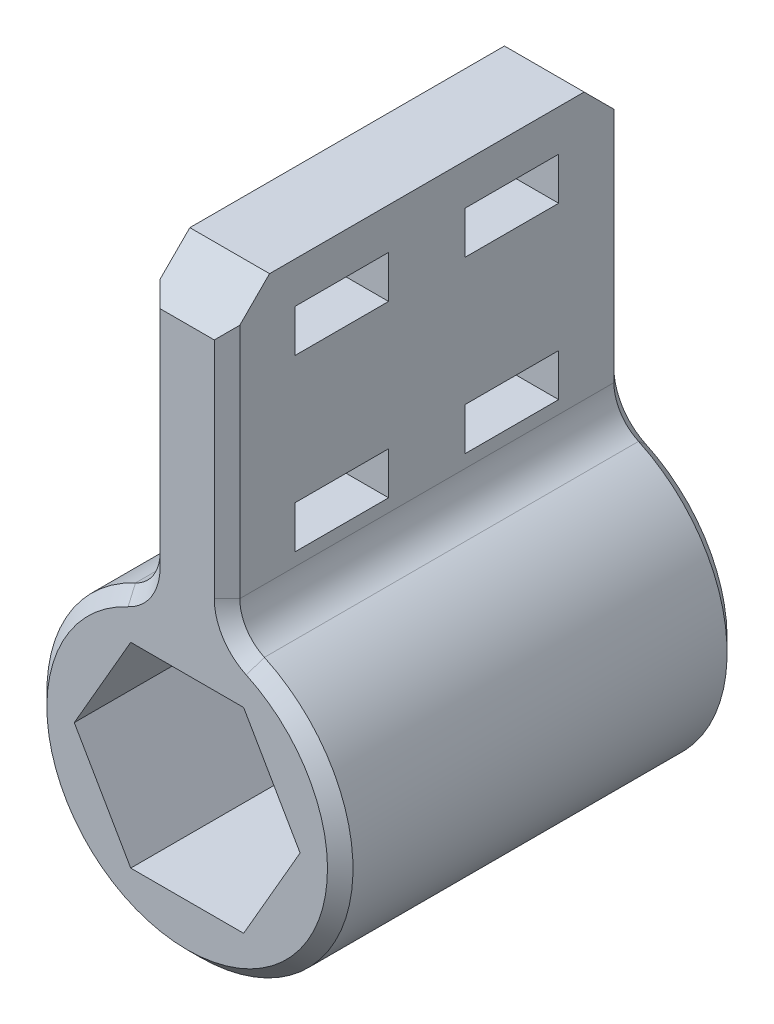
from build123d import *

# Parameters (mm, degrees)
SKETCH2_R           = 3.6
SKETCH2_R_2         = 1.625
BOSS_EXTRUDE1_DEPTH = 9.4
BOSS_EXTRUDE2_DEPTH = 9.4
SKETCH4_W           = 2.2
SKETCH4_H           = 1
CUT_EXTRUDE2_DEPTH  = 10
CHAMFER2_SIZE       = 1
FILLET1_R           = 1
CUT_EXTRUDE3_DEPTH  = 10
CHAMFER1_SIZE       = 0.3


with BuildPart() as part:
    # Sketch2 → Boss-Extrude1 (new body)
    with BuildSketch(Plane.XY):
        Circle(SKETCH2_R)
        Circle(SKETCH2_R_2, mode=Mode.SUBTRACT)
    extrude(amount=BOSS_EXTRUDE1_DEPTH)

    # Sketch3 → Boss-Extrude2 (add)
    with BuildSketch(Plane.XY.offset(9.4)):
        with BuildLine():
            Line((-0.9375, 10.44191444), (-0.9375, 3.475786781))
            ThreePointArc((-0.9375, 3.475786781), (0, 3.6), (0.9375, 3.475786781))
            Line((0.9375, 3.475786781), (0.9375, 10.44191444))
            Line((0.9375, 10.44191444), (-0.9375, 10.44191444))
        make_face()
    extrude(amount=-BOSS_EXTRUDE2_DEPTH)

    # Sketch4 → Cut-Extrude2 (cut)
    with BuildSketch(Plane.ZY.offset(0.9375)):
        with Locations((2.7, 8.975786781)):
            Rectangle(SKETCH4_W, SKETCH4_H)
        with Locations((6.7, 8.975786781)):
            Rectangle(SKETCH4_W, SKETCH4_H)
        with Locations((2.7, 4.975786781)):
            Rectangle(SKETCH4_W, SKETCH4_H)
        with Locations((6.7, 4.975786781)):
            Rectangle(SKETCH4_W, SKETCH4_H)
    extrude(amount=-CUT_EXTRUDE2_DEPTH, mode=Mode.SUBTRACT)

    # Chamfer2
    chamfer2_edges = [part.edges().sort_by_distance(p)[0] for p in [
        (0, 10.44191444, 0),
        (0, 10.44191444, 9.4),
    ]]
    chamfer(chamfer2_edges, length=CHAMFER2_SIZE)

    # Fillet1
    fillet1_edges = [part.edges().sort_by_distance(p)[0] for p in [
        (0.9375, 3.475786781, 4.7),
        (-0.9375, 3.475786781, 4.7),
    ]]
    fillet(fillet1_edges, radius=FILLET1_R)

    # Sketch5 → Cut-Extrude3 (cut)
    with BuildSketch(Plane(origin=(0, 0, 0), x_dir=(-1, 0, 0), z_dir=(0, 0, -1))):
        Polygon((1.327905619, 2.3), (-1.327905619, 2.3), (-2.655811238, 0), (-1.327905619, -2.3), (1.327905619, -2.3), (2.655811238, 0), align=None)
    extrude(amount=-CUT_EXTRUDE3_DEPTH, mode=Mode.SUBTRACT)

    # Chamfer1
    chamfer1_edges = [part.edges().sort_by_distance(p)[0] for p in [
        (0.9375, 6.806987766, 0),
        (-0.9375, 6.806987766, 0),
        (0, -3.6, 0),
        (0, -3.6, 9.4),
        (0.9375, 6.806987766, 9.4),
        (-0.9375, 6.806987766, 9.4),
        (1.094530353, 3.634099965, 9.4),
        (1.094530353, 3.634099965, 0),
        (-1.094530353, 3.634099965, 9.4),
        (-1.094530353, 3.634099965, 0),
    ]]
    chamfer(chamfer1_edges, length=CHAMFER1_SIZE)


solid = part.part
